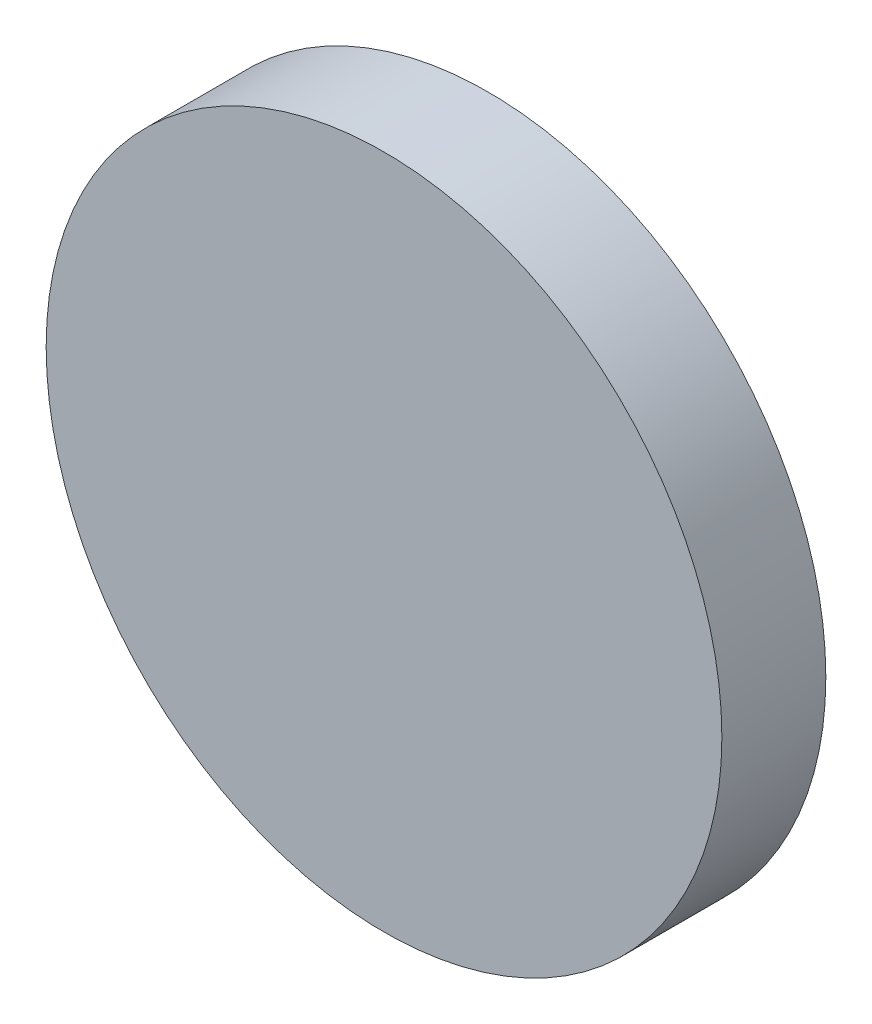
from build123d import *

# Parameters (mm, degrees)
SKETCH_1_R      = 32.5
EXTRUDE_1_DEPTH = 10


with BuildPart() as part:
    # ｽｹｯﾁ1 → ﾎﾞｽ - 押し出し1 (new body)
    with BuildSketch(Plane.XY):
        with Locations((-26.119921857, 17.989620209)):
            Circle(SKETCH_1_R)
    extrude(amount=EXTRUDE_1_DEPTH)


solid = part.part
